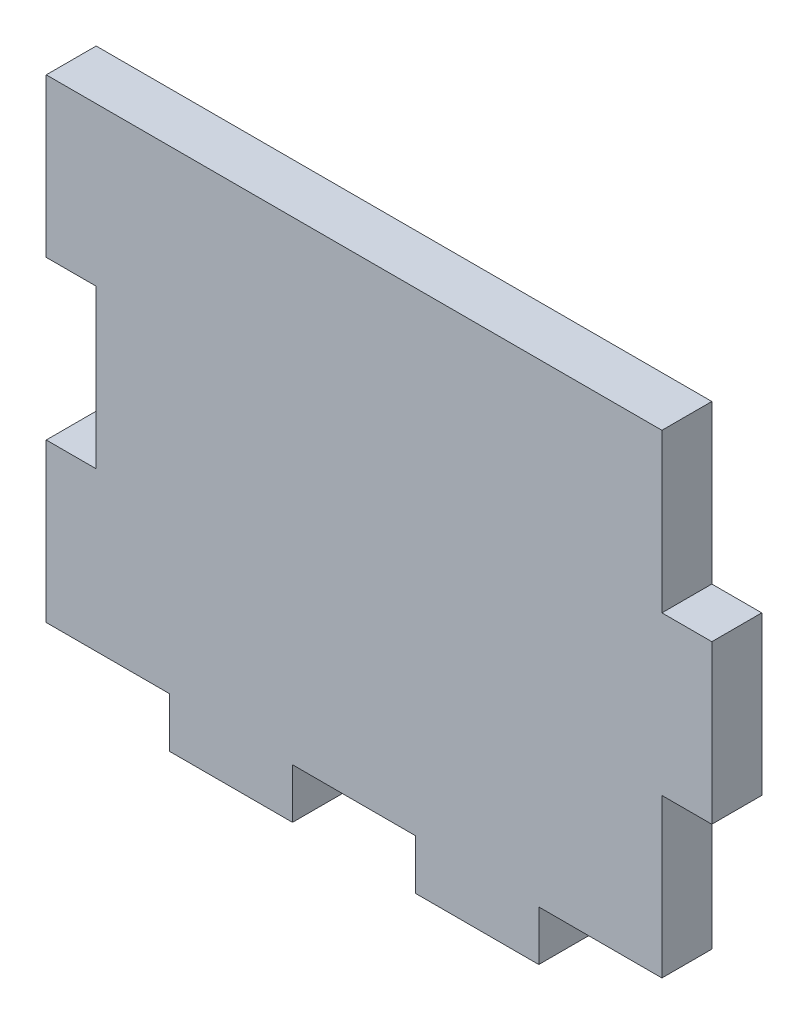
from build123d import *

# Parameters (mm, degrees)
BOSS_EXTRUDE1_DEPTH = 4.5


with BuildPart() as part:
    # Sketch1 → Boss-Extrude1 (new body)
    with BuildSketch(Plane.XY):
        Polygon((22.2, 0), (33.3, 0), (33.3, -4.5), (44.4, -4.5), (44.4, 0), (55.5, 0), (55.5, 14.253333333), (60, 14.253333333), (60, 28.506666667), (55.5, 28.506666667), (55.5, 42.76), (40, 42.76), (20, 42.76), (0, 42.76), (0, 28.506666667), (4.5, 28.506666667), (4.5, 14.253333333), (0, 14.253333333), (0, 0), (11.1, 0), (11.1, -4.5), (22.2, -4.5), align=None)
    extrude(amount=BOSS_EXTRUDE1_DEPTH)


solid = part.part
